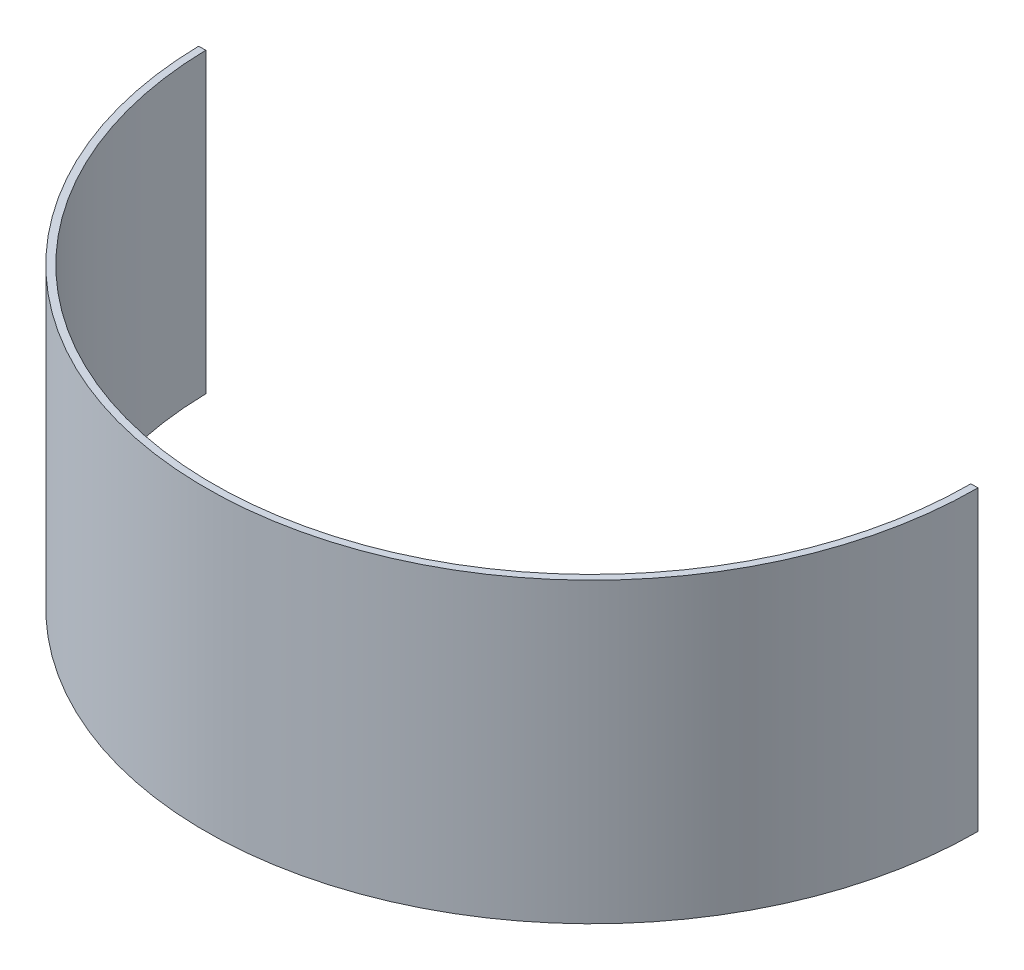
from build123d import *

# Parameters (mm, degrees)
BOSS_EXTRUDE1_DEPTH = 66.675


with BuildPart() as part:
    # Sketch1 → Boss-Extrude1 (new body, symmetric)
    with BuildSketch(Plane(origin=(0, 0, 0), x_dir=(1, 0, 0), z_dir=(0, 1, 0))):
        with BuildLine():
            Line((169.8625, 0), (173.0375, 0))
            ThreePointArc((173.0375, 0), (1.617243533, -173.029942292), (-173.007269829, -3.234345794))
            Line((-173.007269829, -3.234345794), (-169.832824511, -3.175))
            ThreePointArc((-169.832824511, -3.175), (1.58756934, -169.855080966), (169.8625, 0))
        make_face()
    extrude(amount=BOSS_EXTRUDE1_DEPTH, both=True)


solid = part.part
